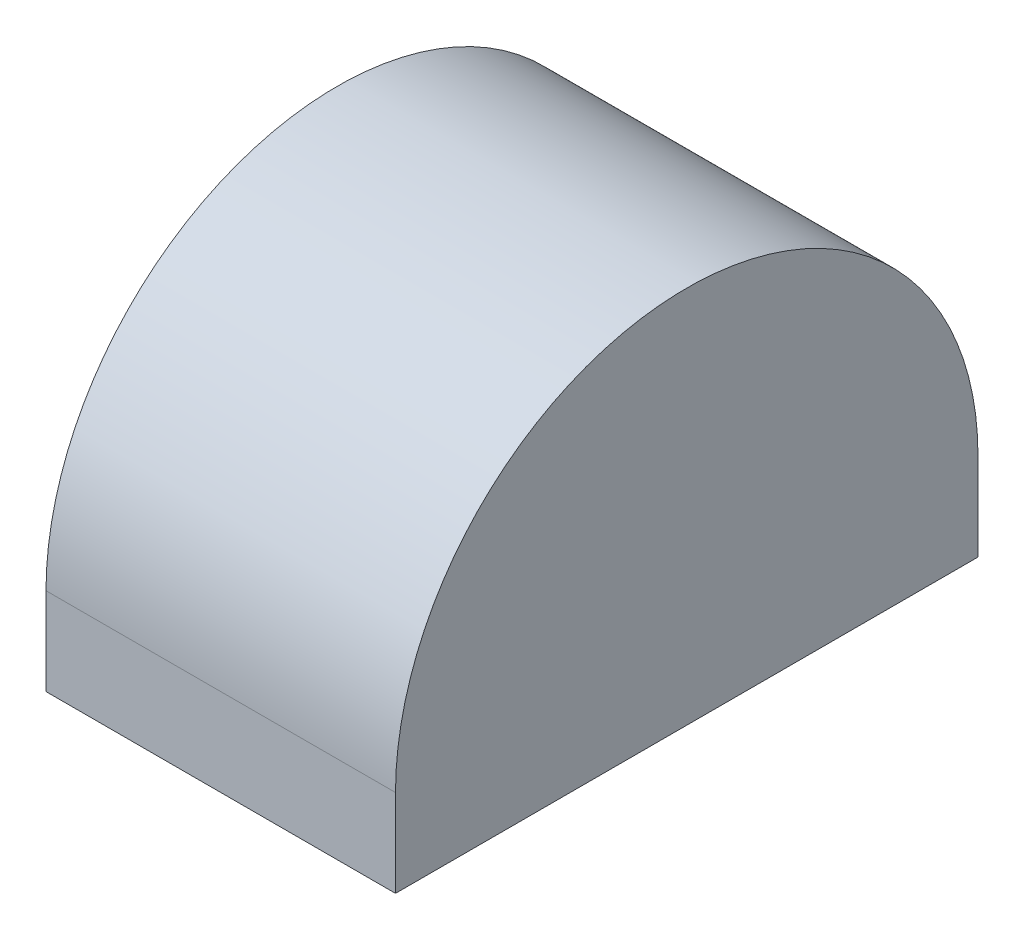
from build123d import *

# Parameters (mm, degrees)
BOSS_EXTRUDE1_DEPTH = 6
CUT_EXTRUDE1_DEPTH  = 3.5


with BuildPart() as part:
    # Sketch1 → Boss-Extrude1 (new body, symmetric)
    with BuildSketch(Plane(origin=(0, 0, 0), x_dir=(0, 0, -1), z_dir=(1, 0, 0))):
        with BuildLine():
            Line((0, 0), (0, 3))
            ThreePointArc((0, 3), (10, 13), (20, 3))
            Line((20, 3), (20, 0))
            Line((20, 0), (0, 0))
        make_face()
    extrude(amount=BOSS_EXTRUDE1_DEPTH, both=True)

    # Sketch2 → Cut-Extrude1 (cut, symmetric)
    with BuildSketch(Plane(origin=(0, 0, 0), x_dir=(0, 0, -1), z_dir=(1, 0, 0))):
        with BuildLine():
            Line((10, 0), (17.5, 0))
            Line((17.5, 0), (17.5, 3))
            ThreePointArc((17.5, 3), (16.532377607, 6.611215932), (13.888784068, 9.254809472))
            Line((13.888784068, 9.254809472), (10, 11.5))
            Line((10, 11.5), (6.111215932, 9.254809472))
            ThreePointArc((6.111215932, 9.254809472), (3.467622393, 6.611215932), (2.5, 3))
            Line((2.5, 3), (2.5, 0))
            Line((2.5, 0), (10, 0))
        make_face()
    extrude(amount=CUT_EXTRUDE1_DEPTH, both=True, mode=Mode.SUBTRACT)


solid = part.part
